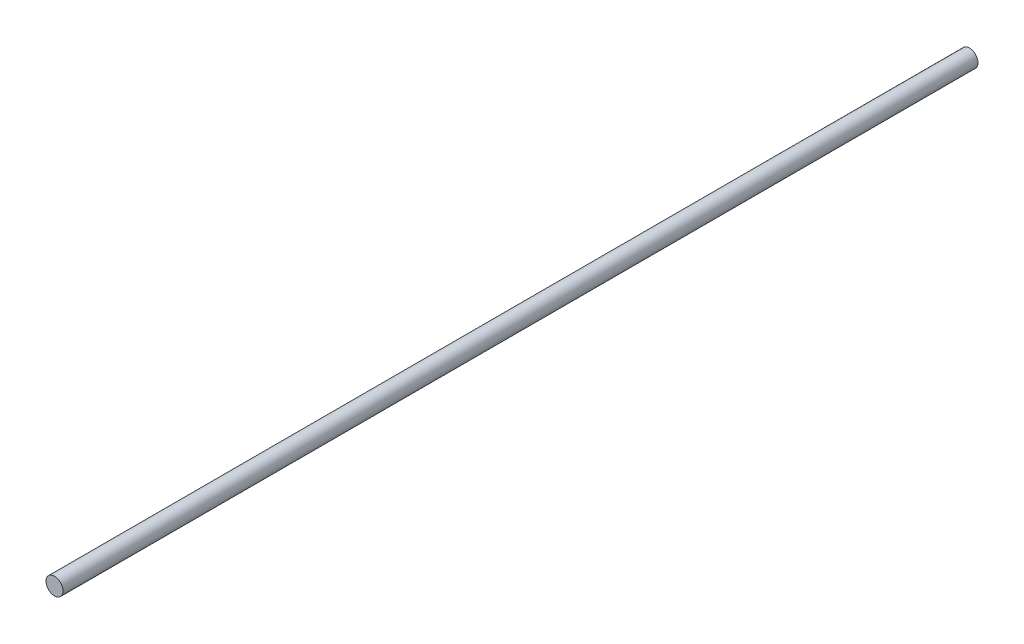
from build123d import *

# Parameters (mm, degrees)
ESQUISSE1_R        = 4
BOSS_EXTRU_1_DEPTH = 428


with BuildPart() as part:
    # Esquisse1 → Boss.-Extru.1 (new body)
    with BuildSketch(Plane.XY):
        Circle(ESQUISSE1_R)
    extrude(amount=BOSS_EXTRU_1_DEPTH)


solid = part.part
